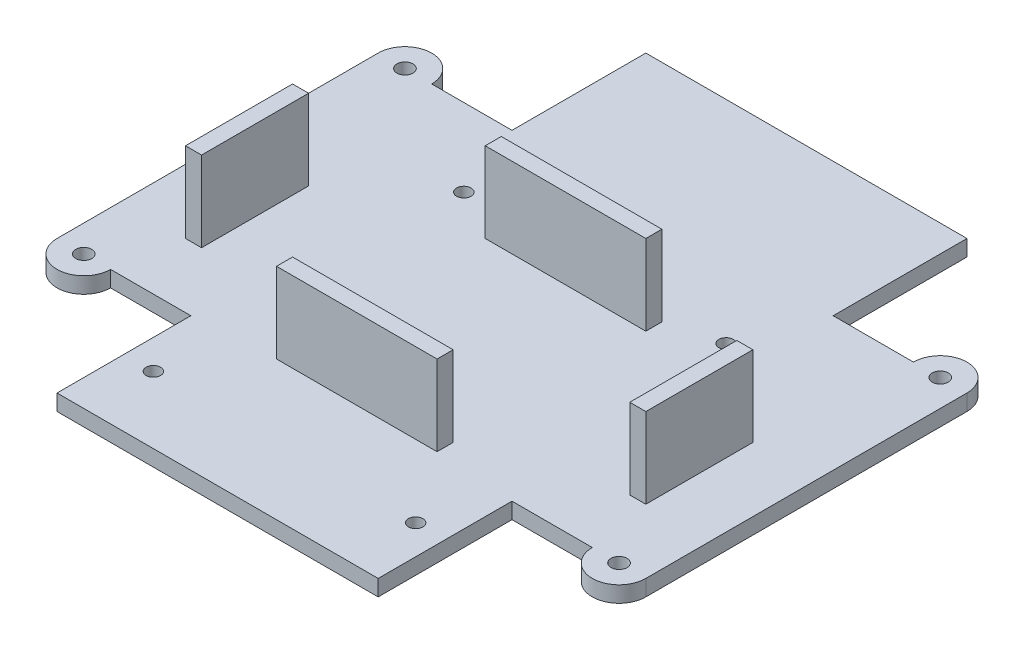
from build123d import *

# Parameters (mm, degrees)
SKETCH2_R           = 1.35
BOSS_EXTRUDE1_DEPTH = 3
SKETCH3_R           = 5
BOSS_EXTRUDE2_DEPTH = 3
SKETCH4_R           = 1.5
CUT_EXTRUDE1_DEPTH  = 4
SKETCH5_W           = 3
SKETCH5_H           = 20
SKETCH5_W_2         = 30
SKETCH5_H_2         = 3
BOSS_EXTRUDE3_DEPTH = 15


with BuildPart() as part:
    # Sketch2 → Boss-Extrude1 (new body)
    with BuildSketch(Plane(origin=(0, 0, 0), x_dir=(1, 0, 0), z_dir=(0, 1, 0))):
        Polygon((30, -55), (-30, -55), (-30, -30), (-55, -30), (-55, 30), (-30, 30), (-30, 55), (30, 55), (30, 30), (55, 30), (55, -30), (30, -30), align=None)
        with Locations((24.5, -42.5)):
            Circle(SKETCH2_R, mode=Mode.SUBTRACT)
        with Locations((-24.5, -42.5)):
            Circle(SKETCH2_R, mode=Mode.SUBTRACT)
        with Locations((24.5, 15.5)):
            Circle(SKETCH2_R, mode=Mode.SUBTRACT)
        with Locations((-24.5, 15.5)):
            Circle(SKETCH2_R, mode=Mode.SUBTRACT)
    extrude(amount=BOSS_EXTRUDE1_DEPTH)

    # Sketch3 → Boss-Extrude2 (add)
    with BuildSketch(Plane(origin=(0, 3, 0), x_dir=(1, 0, 0), z_dir=(0, 1, 0))):
        with Locations((50, 30)):
            Circle(SKETCH3_R)
        with Locations((50, -30)):
            Circle(SKETCH3_R)
        with Locations((-50, -30)):
            Circle(SKETCH3_R)
        with Locations((-50, 30)):
            Circle(SKETCH3_R)
    extrude(amount=-BOSS_EXTRUDE2_DEPTH)

    # Sketch4 → Cut-Extrude1 (cut, through all)
    with BuildSketch(Plane(origin=(0, 3, 0), x_dir=(1, 0, 0), z_dir=(0, 1, 0))):
        with Locations((50, 30)):
            Circle(SKETCH4_R)
        with Locations((50, -30)):
            Circle(SKETCH4_R)
        with Locations((-50, -30)):
            Circle(SKETCH4_R)
        with Locations((-50, 30)):
            Circle(SKETCH4_R)
    extrude(amount=-CUT_EXTRUDE1_DEPTH, mode=Mode.SUBTRACT)

    # Sketch5 → Boss-Extrude3 (add)
    with BuildSketch(Plane(origin=(0, 3, 0), x_dir=(1, 0, 0), z_dir=(0, 1, 0))):
        with Locations((-41.5, -8)):
            Rectangle(SKETCH5_W, SKETCH5_H)
        with Locations((41.5, -8)):
            Rectangle(SKETCH5_W, SKETCH5_H)
        with Locations((0, 11.5)):
            Rectangle(SKETCH5_W_2, SKETCH5_H_2)
        with Locations((0, -27.5)):
            Rectangle(SKETCH5_W_2, SKETCH5_H_2)
    extrude(amount=BOSS_EXTRUDE3_DEPTH)


solid = part.part
